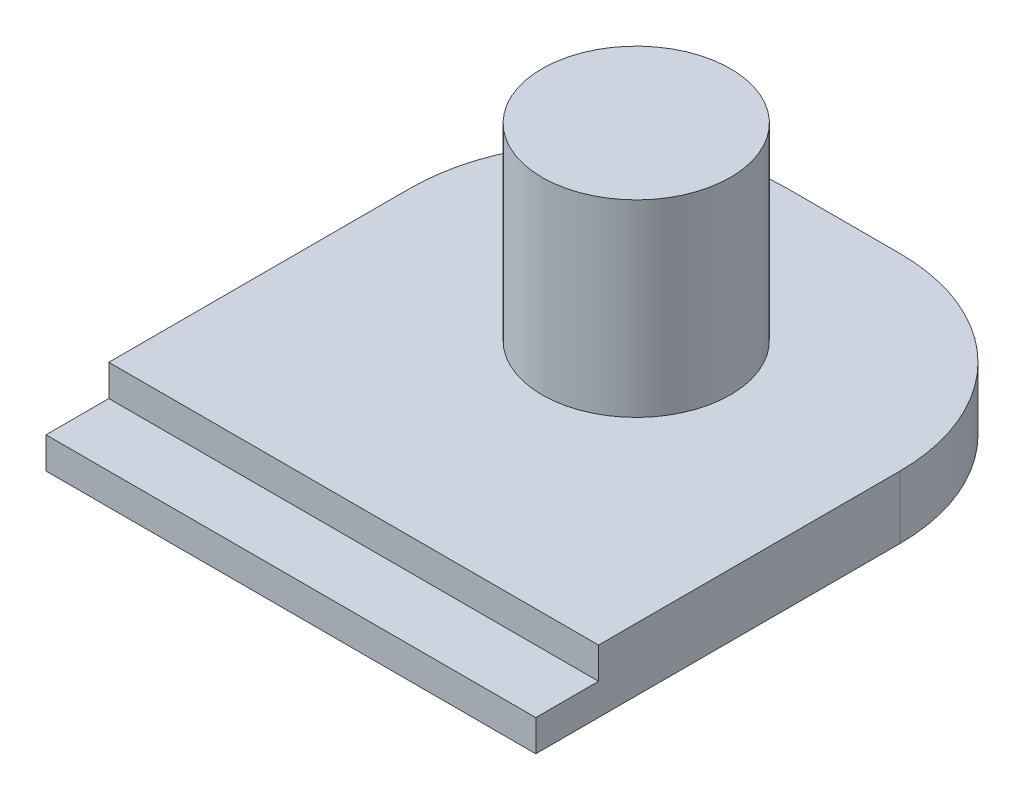
from build123d import *

# Parameters (mm, degrees)
BOSS_EXTRUDE1_DEPTH = 1
SKETCH2_R           = 1.5
BOSS_EXTRUDE2_DEPTH = 3
SKETCH3_W           = 7.8
SKETCH3_H           = 1
CUT_EXTRUDE1_DEPTH  = 0.5


with BuildPart() as part:
    # Sketch1 → Boss-Extrude1 (new body)
    with BuildSketch(Plane(origin=(0, 0, 0), x_dir=(1, 0, 0), z_dir=(0, 1, 0))):
        with BuildLine():
            Line((0, 0), (7.8, 0))
            Line((7.8, 0), (7.8, 5.8))
            ThreePointArc((7.8, 5.8), (6.921320344, 7.921320344), (4.8, 8.8))
            Line((4.8, 8.8), (3, 8.8))
            ThreePointArc((3, 8.8), (0.878679656, 7.921320344), (0, 5.8))
            Line((0, 5.8), (0, 0))
        make_face()
    extrude(amount=BOSS_EXTRUDE1_DEPTH)

    # Sketch2 → Boss-Extrude2 (add)
    with BuildSketch(Plane(origin=(0, 1, 0), x_dir=(1, 0, 0), z_dir=(0, 1, 0))):
        with Locations((3.9, 5.5)):
            Circle(SKETCH2_R)
    extrude(amount=BOSS_EXTRUDE2_DEPTH)

    # Sketch3 → Cut-Extrude1 (cut)
    with BuildSketch(Plane(origin=(0, 1, 0), x_dir=(1, 0, 0), z_dir=(0, 1, 0))):
        with Locations((3.9, 0.5)):
            Rectangle(SKETCH3_W, SKETCH3_H)
    extrude(amount=-CUT_EXTRUDE1_DEPTH, mode=Mode.SUBTRACT)


solid = part.part
